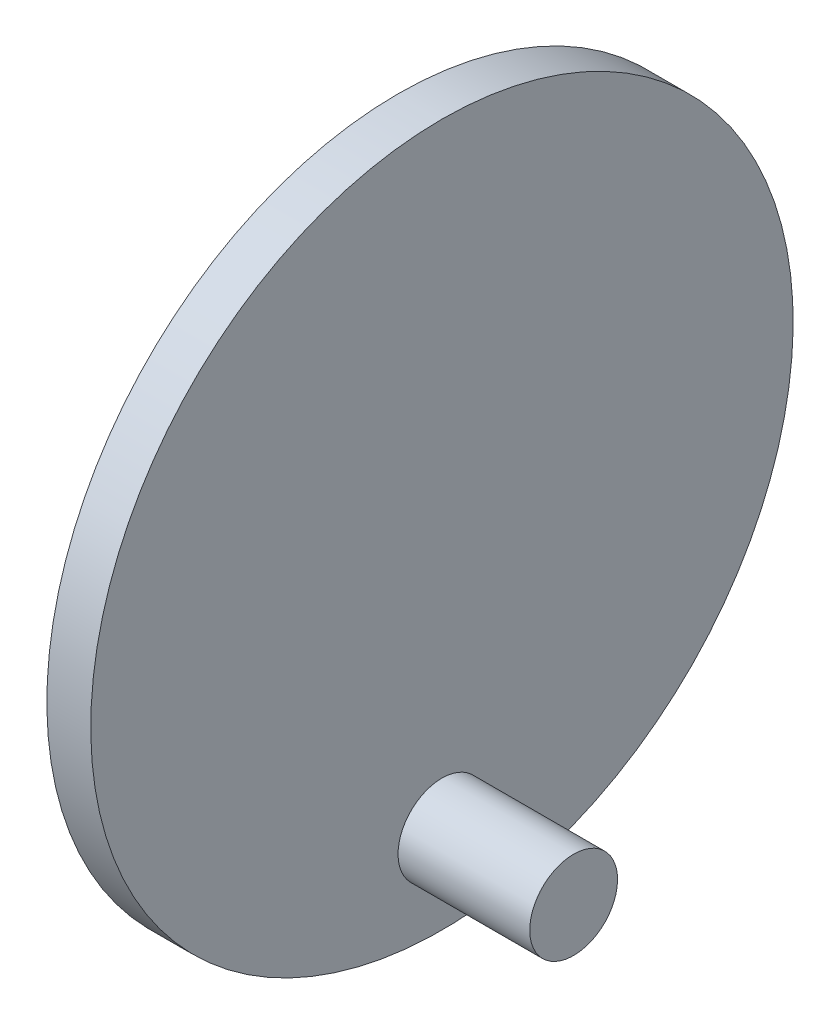
from build123d import *

# Parameters (mm, degrees)
SKETCH2_R                = 7.5
BOSS_EXTRUDE1_DEPTH      = 5
BOSS_EXTRUDE1_DEPTH_BACK = 15
SKETCH3_R                = 40
BOSS_EXTRUDE2_DEPTH      = 5
SKETCH4_R                = 5
BOSS_EXTRUDE3_DEPTH      = 15


with BuildPart() as part:
    # Sketch2 → Boss-Extrude1 (new body, two sides)
    with BuildSketch(Plane(origin=(10, 0, 0), x_dir=(0, 0, -1), z_dir=(1, 0, 0))) as boss_extrude1_sk:
        with Locations((0, 60)):
            Circle(SKETCH2_R)
    extrude(amount=BOSS_EXTRUDE1_DEPTH)
    extrude(boss_extrude1_sk.sketch, amount=-BOSS_EXTRUDE1_DEPTH_BACK)

    # Sketch3 → Boss-Extrude2 (add)
    with BuildSketch(Plane(origin=(15, 0, 0), x_dir=(0, 0, -1), z_dir=(1, 0, 0))):
        with Locations((0, 60)):
            Circle(SKETCH3_R)
    extrude(amount=BOSS_EXTRUDE2_DEPTH)

    # Sketch4 → Boss-Extrude3 (add)
    with BuildSketch(Plane(origin=(20, 0, 0), x_dir=(0, 0, -1), z_dir=(1, 0, 0))):
        with Locations((0, 30)):
            Circle(SKETCH4_R)
    extrude(amount=BOSS_EXTRUDE3_DEPTH)


solid = part.part
